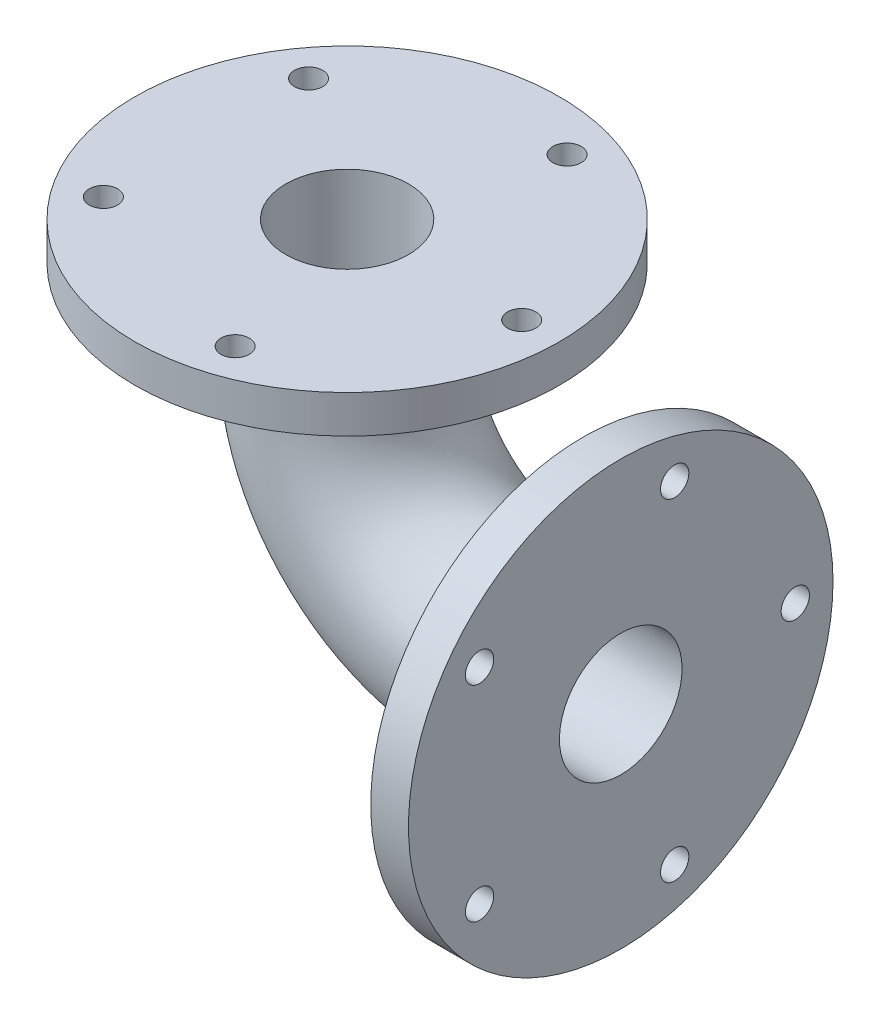
from build123d import *

# Parameters (mm, degrees)
SKETCH2_R           = 48.5
SKETCH3_R           = 112.5
BOSS_EXTRUDE1_DEPTH = 20
SKETCH4_R           = 112.5
BOSS_EXTRUDE2_DEPTH = 20
SKETCH5_R           = 32.5
SKETCH6_R           = 7.5
CUT_EXTRUDE1_DEPTH  = 30
SKETCH7_R           = 7.5
CUT_EXTRUDE3_DEPTH  = 30


with BuildPart() as part:
    # Sweep1: sweep along a path in Sketch1
    with BuildLine(Plane.XY) as sweep1_path:
        Line((0, 0), (-55, 0))
        ThreePointArc((-55, 0), (-118.639610307, 26.360389693), (-145, 90))
        Line((-145, 90), (-145, 150))
    # Sketch2 → Sweep1 (sweep)
    with BuildSketch(Plane(origin=(0, 0, 0), x_dir=(0, 0, -1), z_dir=(1, 0, 0))):
        Circle(SKETCH2_R)
    sweep(path=sweep1_path.line)

    # Sketch3 → Boss-Extrude1 (add)
    with BuildSketch(Plane(origin=(0, 0, 0), x_dir=(0, 0, -1), z_dir=(1, 0, 0))):
        Circle(SKETCH3_R)
    extrude(amount=-BOSS_EXTRUDE1_DEPTH)

    # Sketch4 → Boss-Extrude2 (add)
    with BuildSketch(Plane(origin=(0, 150, 0), x_dir=(1, 0, 0), z_dir=(0, 1, 0))):
        with Locations((-145, 0)):
            Circle(SKETCH4_R)
    extrude(amount=-BOSS_EXTRUDE2_DEPTH)

    # Cut-Sweep1: sweep along a path in Sketch1_2
    with BuildLine(Plane.XY) as cut_sweep1_path:
        Line((0, 0), (-55, 0))
        ThreePointArc((-55, 0), (-118.639610307, 26.360389693), (-145, 90))
        Line((-145, 90), (-145, 150))
    # Sketch5 → Cut-Sweep1 (sweep, cut)
    with BuildSketch(Plane(origin=(0, 0, 0), x_dir=(0, 0, -1), z_dir=(1, 0, 0))):
        Circle(SKETCH5_R)
    sweep(path=cut_sweep1_path.line, mode=Mode.SUBTRACT)

    # Sketch6 → Cut-Extrude1 (cut)
    with BuildSketch(Plane(origin=(0, 150, 0), x_dir=(1, 0, 0), z_dir=(0, 1, 0))):
        with Locations((-52.5, 0)):
            Circle(SKETCH6_R)
        with Locations((-116.41592802, -87.972727757)):
            Circle(SKETCH6_R)
        with Locations((-219.83407198, -54.370135837)):
            Circle(SKETCH6_R)
        with Locations((-219.83407198, 54.370135837)):
            Circle(SKETCH6_R)
        with Locations((-116.41592802, 87.972727757)):
            Circle(SKETCH6_R)
    extrude(amount=-CUT_EXTRUDE1_DEPTH, mode=Mode.SUBTRACT)

    # Sketch7 → Cut-Extrude3 (cut)
    with BuildSketch(Plane(origin=(0, 0, 0), x_dir=(0, 0, -1), z_dir=(1, 0, 0))):
        with Locations((92.5, 0)):
            Circle(SKETCH7_R)
        with Locations((28.58407198, -87.972727757)):
            Circle(SKETCH7_R)
        with Locations((-74.83407198, -54.370135837)):
            Circle(SKETCH7_R)
        with Locations((-74.83407198, 54.370135837)):
            Circle(SKETCH7_R)
        with Locations((28.58407198, 87.972727757)):
            Circle(SKETCH7_R)
    extrude(amount=-CUT_EXTRUDE3_DEPTH, mode=Mode.SUBTRACT)


solid = part.part
